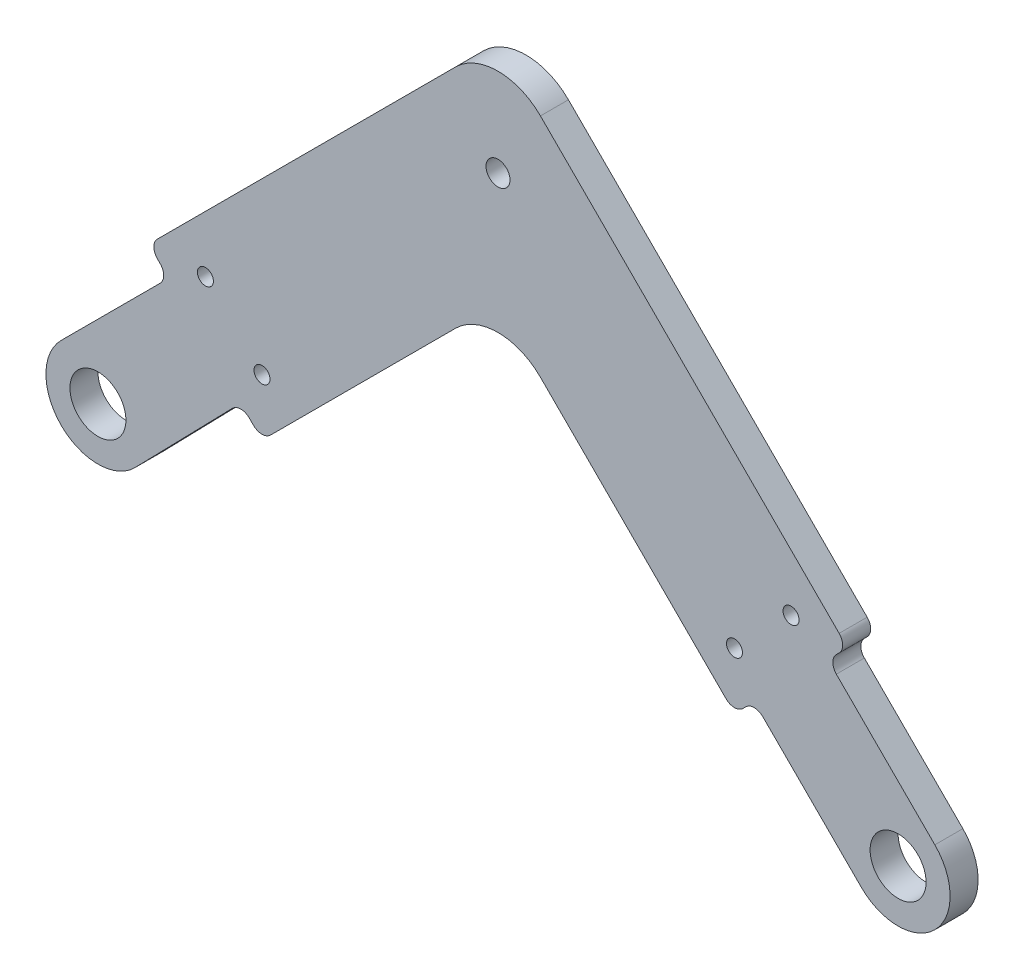
from build123d import *

# Parameters (mm, degrees)
SKETCH7_R           = 3.5
SKETCH7_R_2         = 1
SKETCH7_R_3         = 1.5
BOSS_EXTRUDE1_DEPTH = 3.5
FILLET1_R           = 7.5
FILLET2_R           = 7.5
FILLET3_R           = 1.5
FILLET4_R           = 1.5
FILLET5_R           = 1.5


with BuildPart() as part:
    # Sketch7 → Boss-Extrude1 (new body)
    with BuildSketch(Plane.XY):
        with BuildLine():
            Line((-91.161165235, 18.03122292), (-104.596194078, 4.596194078))
            ThreePointArc((-104.596194078, 4.596194078), (-104.565177968, -4.627002282), (-95.342398812, -4.533955357))
            Line((-95.342398812, -4.533955357), (-82.149090724, 9.019148409))
            Line((-82.149090724, 9.019148409), (-79.493903346, 6.363961031))
            Line((-79.493903346, 6.363961031), (-50, 35.857864376))
            Line((-50, 35.857864376), (-20.445483687, 6.303348063))
            Line((-20.445483687, 6.303348063), (-17.970609953, 8.778221797))
            Line((-17.970609953, 8.778221797), (-4.596194078, -4.596194078))
            ThreePointArc((-4.596194078, -4.596194078), (4.596194078, -4.596194078), (4.596194078, 4.596194078))
            Line((4.596194078, 4.596194078), (-8.778221797, 17.970609953))
            Line((-8.778221797, 17.970609953), (-6.303348063, 20.445483687))
            Line((-6.303348063, 20.445483687), (-50, 64.142135624))
            Line((-50, 64.142135624), (-93.636038969, 20.506096654))
            Line((-93.636038969, 20.506096654), (-91.161165235, 18.03122292))
        make_face()
        Circle(SKETCH7_R, mode=Mode.SUBTRACT)
        with Locations((-100, 0)):
            Circle(SKETCH7_R, mode=Mode.SUBTRACT)
        with Locations((-86.564971157, 20.506096654)):
            Circle(SKETCH7_R_2, mode=Mode.SUBTRACT)
        with Locations((-50, 50)):
            Circle(SKETCH7_R_3, mode=Mode.SUBTRACT)
        with Locations((-13.374415875, 20.445483687)):
            Circle(SKETCH7_R_2, mode=Mode.SUBTRACT)
        with Locations((-20.445483687, 13.374415875)):
            Circle(SKETCH7_R_2, mode=Mode.SUBTRACT)
        with Locations((-79.493903346, 13.435028843)):
            Circle(SKETCH7_R_2, mode=Mode.SUBTRACT)
    extrude(amount=BOSS_EXTRUDE1_DEPTH)

    # Fillet1
    fillet1_edges = [part.edges().sort_by_distance(p)[0] for p in [
        (-50, 64.142135624, 1.75),
    ]]
    fillet(fillet1_edges, radius=FILLET1_R)

    # Fillet2
    fillet2_edges = [part.edges().sort_by_distance(p)[0] for p in [
        (-50, 35.857864376, 1.75),
    ]]
    fillet(fillet2_edges, radius=FILLET2_R)

    # Fillet3
    fillet3_edges = [part.edges().sort_by_distance(p)[0] for p in [
        (-82.149090724, 9.019148409, 1.75),
        (-93.636038969, 20.506096654, 1.75),
        (-17.970609953, 8.778221797, 1.75),
        (-20.445483687, 6.303348063, 1.75),
        (-79.493903346, 6.363961031, 1.75),
    ]]
    fillet(fillet3_edges, radius=FILLET3_R)

    # Fillet4
    fillet4_edges = [part.edges().sort_by_distance(p)[0] for p in [
        (-6.303348063, 20.445483687, 1.75),
        (-8.778221797, 17.970609953, 1.75),
    ]]
    fillet(fillet4_edges, radius=FILLET4_R)

    # Fillet5
    fillet5_edges = [part.edges().sort_by_distance(p)[0] for p in [
        (-91.161165235, 18.03122292, 1.75),
    ]]
    fillet(fillet5_edges, radius=FILLET5_R)


solid = part.part
